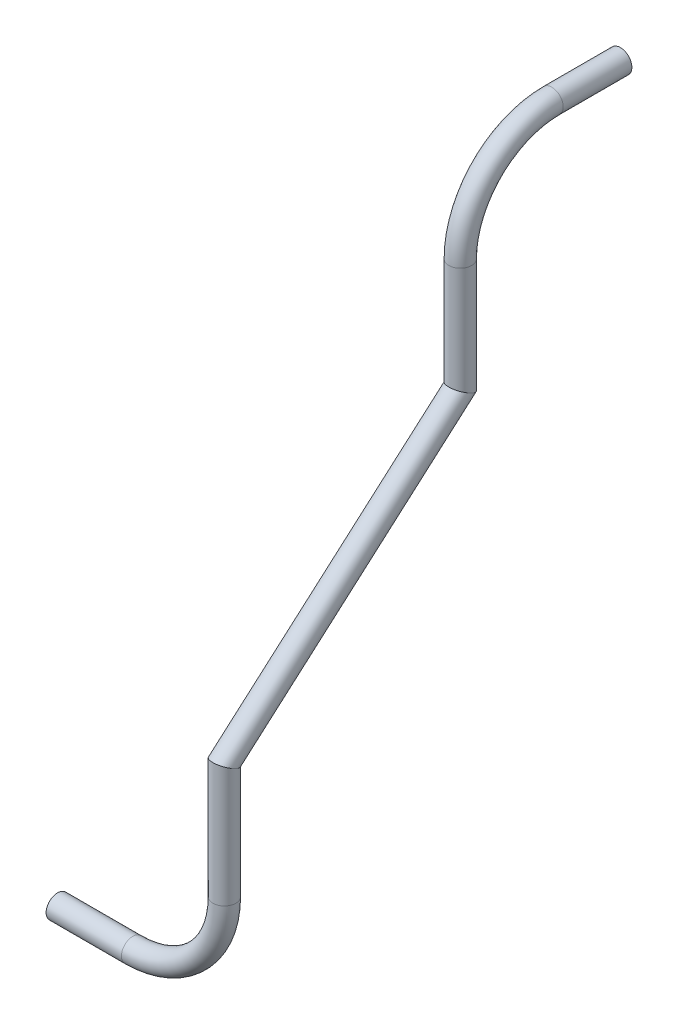
from build123d import *

# Parameters (mm, degrees)
SKETCH1_R                 = 6.35
SKETCH1_R_2               = 5.2832
PIPE_0_5_SCH_40_1_DEPTH   = 41.795098371
SKETCH1_ON_SEGMENT_2_R    = 6.35
SKETCH1_ON_SEGMENT_2_R_2  = 5.2832
PIPE_0_5_SCH_40_1_2_ANGLE = 90
SKETCH1_ON_SEGMENT_3_R    = 6.35
SKETCH1_ON_SEGMENT_3_R_2  = 5.2832
PIPE_0_5_SCH_40_1_3_DEPTH = 69.79896702
SKETCH1_ON_SEGMENT_4_R    = 6.35
SKETCH1_ON_SEGMENT_4_R_2  = 5.2832
PIPE_0_5_SCH_40_1_4_DEPTH = 184.468027015
SKETCH1_ON_SEGMENT_5_R    = 6.35
SKETCH1_ON_SEGMENT_5_R_2  = 5.2832
PIPE_0_5_SCH_40_1_5_DEPTH = 66.375720213
SKETCH1_ON_SEGMENT_6_R    = 6.35
SKETCH1_ON_SEGMENT_6_R_2  = 5.2832
PIPE_0_5_SCH_40_1_6_ANGLE = 90
SKETCH1_ON_SEGMENT_7_R    = 6.35
SKETCH1_ON_SEGMENT_7_R_2  = 5.2832
PIPE_0_5_SCH_40_1_7_DEPTH = 38.1


with BuildPart() as part:
    # Sketch1 → Pipe 0.5 SCH 40(1) (new body)
    with BuildSketch(Plane(origin=(-402.785662915, 1382.243937985, 528.675597351), x_dir=(0, 0, -1), z_dir=(1, 0, 0))):
        Circle(SKETCH1_R)
        Circle(SKETCH1_R_2, mode=Mode.SUBTRACT)
    extrude(amount=PIPE_0_5_SCH_40_1_DEPTH)


with BuildPart() as body_2:
    # Sketch1 on segment 2 (carried to the start of arc 2) → Pipe 0.5 SCH 40_1 2 (revolve)
    with BuildSketch(Plane(origin=(-360.990564544, 1382.243937985, 528.675597351), x_dir=(0, 0, -1), z_dir=(1, 0, 0))):
        Circle(SKETCH1_ON_SEGMENT_2_R)
        Circle(SKETCH1_ON_SEGMENT_2_R_2, mode=Mode.SUBTRACT)
    revolve(axis=Axis((-360.990564544, 1433.043937985, 528.675597351), (0, 0, 1)), revolution_arc=PIPE_0_5_SCH_40_1_2_ANGLE)


with BuildPart() as body_3:
    # Sketch1 on segment 3 (carried to segment 3) → Pipe 0.5 SCH 40_1 3 (new body)
    with BuildSketch(Plane(origin=(-310.190564544, 1433.043937985, 528.675597351), x_dir=(0, 0, -1), z_dir=(0, 1, 0))):
        Circle(SKETCH1_ON_SEGMENT_3_R)
        Circle(SKETCH1_ON_SEGMENT_3_R_2, mode=Mode.SUBTRACT)
    extrude(amount=PIPE_0_5_SCH_40_1_3_DEPTH)

    # Pipe 0.5 SCH 40_1 3 mitre 1
    split(bisect_by=Plane(origin=(-310.190564544, 1497.778816385, 528.675597351), x_dir=(0.999999999, 3.623e-05, 0), z_dir=(3.3007e-05, -0.911047269, 0.412301919)), keep=Keep.TOP)


with BuildPart() as body_4:
    # Sketch1 on segment 4 (carried to segment 4) → Pipe 0.5 SCH 40_1 4 (new body)
    with BuildSketch(Plane(origin=(-310.190259977, 1494.436445714, 532.480009494), x_dir=(-0.751253074, -0.49586756, -0.435584873), z_dir=(-6.0142e-05, 0.660014254, -0.751253074))):
        Circle(SKETCH1_ON_SEGMENT_4_R)
        Circle(SKETCH1_ON_SEGMENT_4_R_2, mode=Mode.SUBTRACT)
    extrude(amount=PIPE_0_5_SCH_40_1_4_DEPTH)

    # Pipe 0.5 SCH 40_1 4 mitre 1
    split(bisect_by=Plane(origin=(-310.190564544, 1497.778816385, 528.675597351), x_dir=(-0.999999999, -3.623e-05, 0), z_dir=(-3.3007e-05, 0.911047269, -0.412301919)), keep=Keep.TOP)

    # Pipe 0.5 SCH 40_1 4 mitre 2
    split(bisect_by=Plane(origin=(-310.201049777, 1612.845602233, 397.702249283), x_dir=(0.999999999, 3.623e-05, 0), z_dir=(3.3007e-05, -0.911047269, 0.412301919)), keep=Keep.TOP)


with BuildPart() as body_5:
    # Sketch1 on segment 5 (carried to segment 5) → Pipe 0.5 SCH 40_1 5 (new body)
    with BuildSketch(Plane(origin=(-310.201049777, 1607.781513613, 397.702249283), x_dir=(0, 0, -1), z_dir=(0, 1, 0))):
        Circle(SKETCH1_ON_SEGMENT_5_R)
        Circle(SKETCH1_ON_SEGMENT_5_R_2, mode=Mode.SUBTRACT)
    extrude(amount=PIPE_0_5_SCH_40_1_5_DEPTH)

    # Pipe 0.5 SCH 40_1 5 mitre 1
    split(bisect_by=Plane(origin=(-310.201049777, 1612.845602233, 397.702249283), x_dir=(-0.999999999, -3.623e-05, 0), z_dir=(-3.3007e-05, 0.911047269, -0.412301919)), keep=Keep.TOP)


with BuildPart() as body_6:
    # Sketch1 on segment 6 (carried to the start of arc 6) → Pipe 0.5 SCH 40_1 6 (revolve)
    with BuildSketch(Plane(origin=(-310.201049777, 1674.157233826, 397.702249283), x_dir=(0, 0, -1), z_dir=(0, 1, 0))):
        Circle(SKETCH1_ON_SEGMENT_6_R)
        Circle(SKETCH1_ON_SEGMENT_6_R_2, mode=Mode.SUBTRACT)
    revolve(axis=Axis((-310.201049777, 1674.157233826, 346.902249283), (-1, 0, 0)), revolution_arc=PIPE_0_5_SCH_40_1_6_ANGLE)


with BuildPart() as body_7:
    # Sketch1 on segment 7 (carried to segment 7) → Pipe 0.5 SCH 40_1 7 (new body)
    with BuildSketch(Plane(origin=(-310.201049777, 1724.957233826, 346.902249283), x_dir=(-1, 0, 0), z_dir=(0, 0, -1))):
        Circle(SKETCH1_ON_SEGMENT_7_R)
        Circle(SKETCH1_ON_SEGMENT_7_R_2, mode=Mode.SUBTRACT)
    extrude(amount=PIPE_0_5_SCH_40_1_7_DEPTH)


solid = Compound([part.part, body_2.part, body_3.part, body_4.part, body_5.part, body_6.part, body_7.part])
